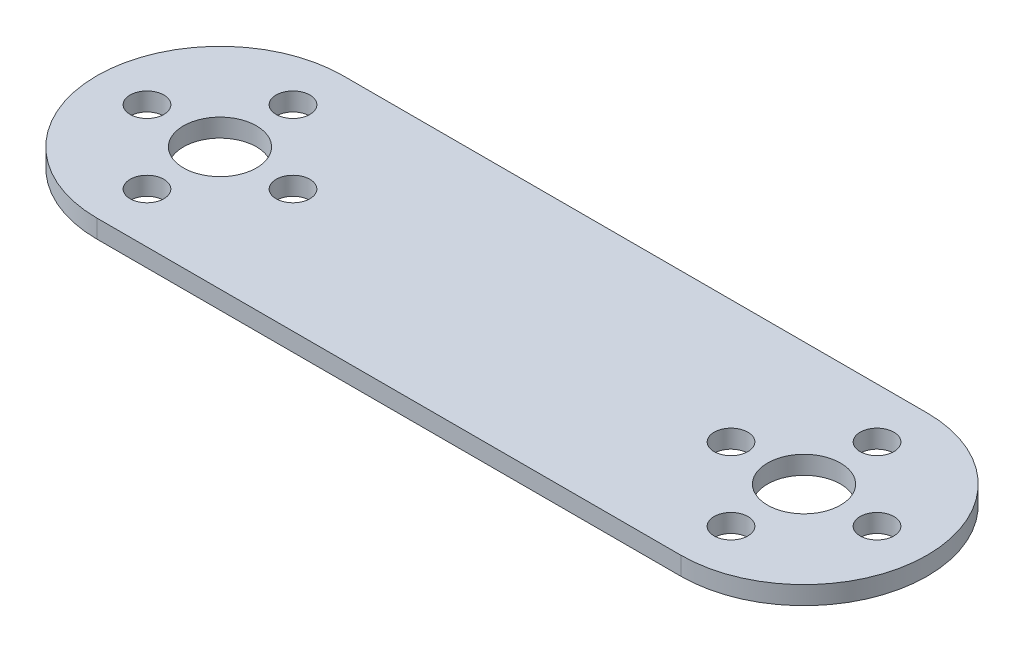
from build123d import *

# Parameters (mm, degrees)
SKETCH1_R           = 1.85
SKETCH1_R_2         = 4
BOSS_EXTRUDE1_DEPTH = 2


with BuildPart() as part:
    # Sketch1 → Boss-Extrude1 (new body)
    with BuildSketch(Plane(origin=(0, 2, 0), x_dir=(1, 0, 0), z_dir=(0, 1, 0))):
        with BuildLine():
            Line((64, 13.5), (0, 13.5))
            ThreePointArc((0, 13.5), (-13.5, 0), (0, -13.5))
            Line((0, -13.5), (64, -13.5))
            ThreePointArc((64, -13.5), (77.5, 0), (64, 13.5))
        make_face()
        with Locations((56, 0)):
            Circle(SKETCH1_R, mode=Mode.SUBTRACT)
        with Locations((64, -8)):
            Circle(SKETCH1_R, mode=Mode.SUBTRACT)
        with Locations((72, 0)):
            Circle(SKETCH1_R, mode=Mode.SUBTRACT)
        with Locations((64, 8)):
            Circle(SKETCH1_R, mode=Mode.SUBTRACT)
        with Locations((64, 0)):
            Circle(SKETCH1_R_2, mode=Mode.SUBTRACT)
        with Locations((-8, 0)):
            Circle(SKETCH1_R, mode=Mode.SUBTRACT)
        with Locations((0, -8)):
            Circle(SKETCH1_R, mode=Mode.SUBTRACT)
        with Locations((8, 0)):
            Circle(SKETCH1_R, mode=Mode.SUBTRACT)
        with Locations((0, 8)):
            Circle(SKETCH1_R, mode=Mode.SUBTRACT)
        Circle(SKETCH1_R_2, mode=Mode.SUBTRACT)
    extrude(amount=-BOSS_EXTRUDE1_DEPTH)


solid = part.part
